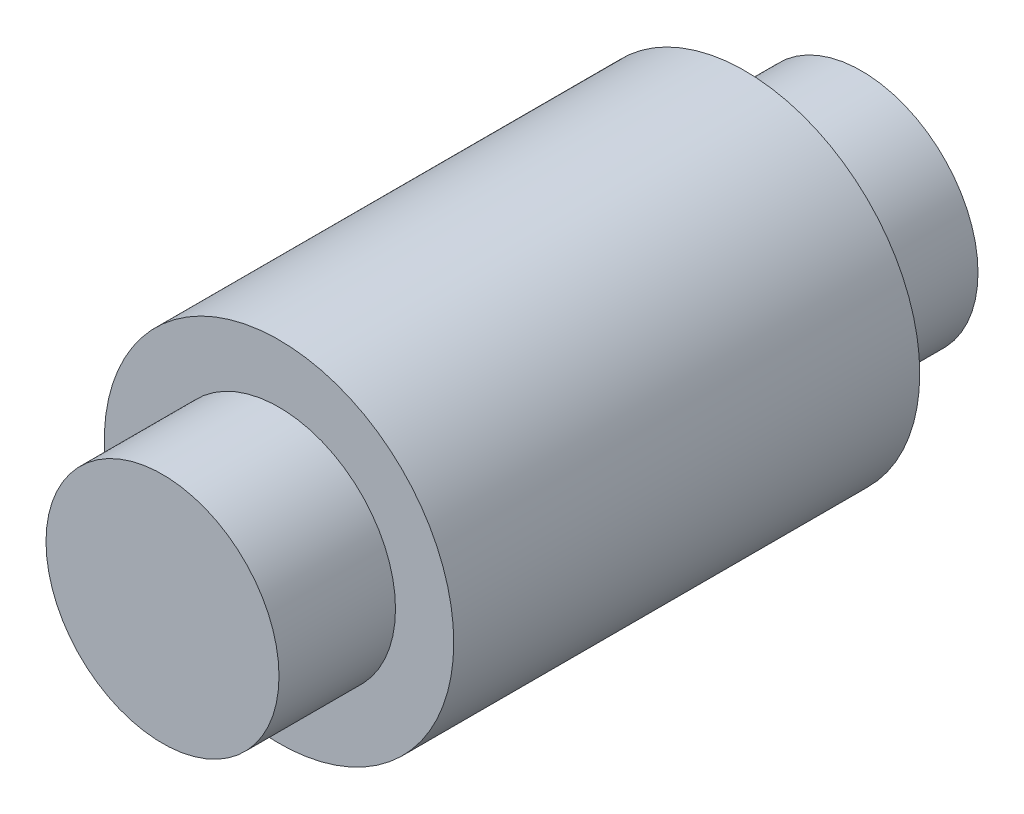
from build123d import *

# Parameters (mm, degrees)
SKETCH1_R           = 7.5
BOSS_EXTRUDE1_DEPTH = 10
SKETCH2_R           = 5
BOSS_EXTRUDE2_DEPTH = 15


with BuildPart() as part:
    # Sketch1 → Boss-Extrude1 (new body, symmetric)
    with BuildSketch(Plane.XY):
        Circle(SKETCH1_R)
    extrude(amount=BOSS_EXTRUDE1_DEPTH, both=True)

    # Sketch2 → Boss-Extrude2 (add, symmetric)
    with BuildSketch(Plane.XY):
        Circle(SKETCH2_R)
    extrude(amount=BOSS_EXTRUDE2_DEPTH, both=True)


solid = part.part
